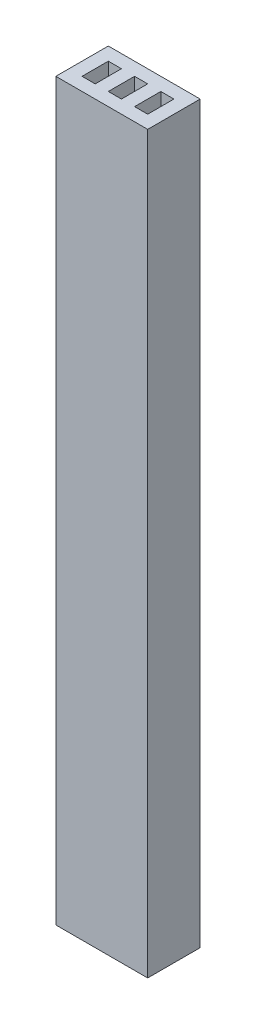
from build123d import *

# Parameters (mm, degrees)
SKETCH1_W           = 7
SKETCH1_H           = 4
SKETCH1_W_2         = 1
SKETCH1_H_2         = 2
BOSS_EXTRUDE1_DEPTH = 56


with BuildPart() as part:
    # Sketch1 → Boss-Extrude1 (new body)
    with BuildSketch(Plane(origin=(0, 0, 0), x_dir=(1, 0, 0), z_dir=(0, 1, 0))):
        with Locations((2.5, 1)):
            Rectangle(SKETCH1_W, SKETCH1_H)
        with Locations((0.5, 1)):
            Rectangle(SKETCH1_W_2, SKETCH1_H_2, mode=Mode.SUBTRACT)
        with Locations((2.5, 1)):
            Rectangle(SKETCH1_W_2, SKETCH1_H_2, mode=Mode.SUBTRACT)
        with Locations((4.5, 1)):
            Rectangle(SKETCH1_W_2, SKETCH1_H_2, mode=Mode.SUBTRACT)
    extrude(amount=BOSS_EXTRUDE1_DEPTH)


solid = part.part
